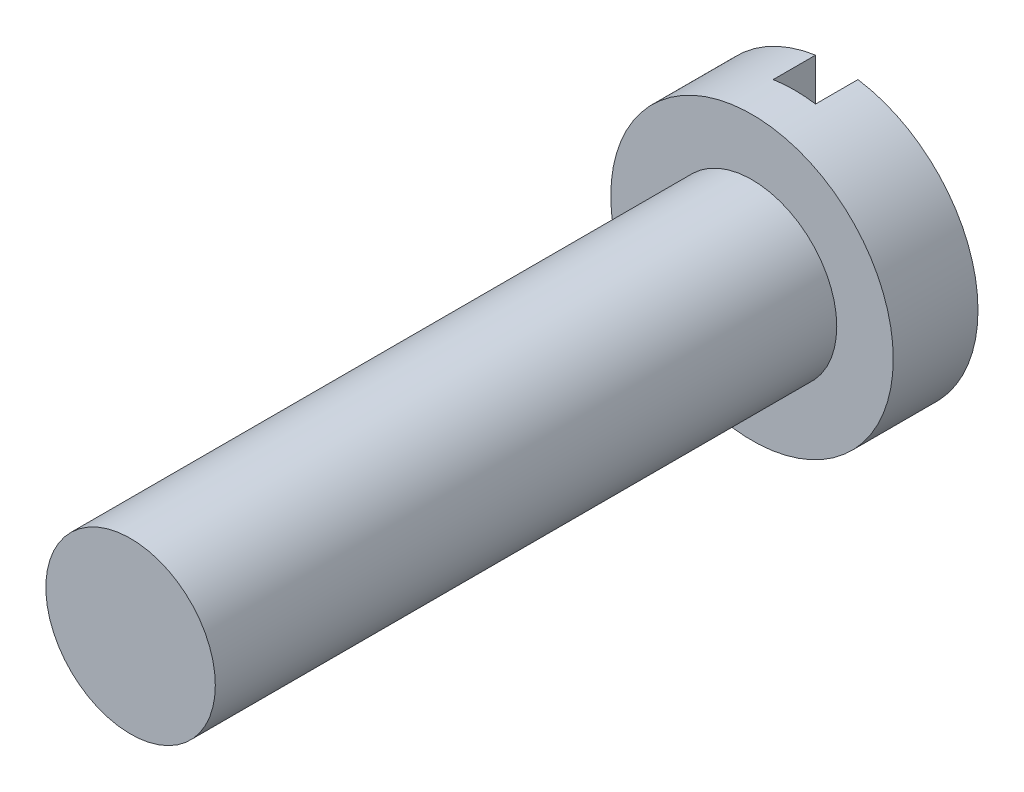
from build123d import *

# Parameters (mm, degrees)
SKETCH_1_R          = 3
EXTRUDE_1_DEPTH     = 22
SKETCH_1_3_R        = 5
EXTRUDE_2_DEPTH     = 3
SKETCH_2_W          = 1.5
SKETCH_2_H          = 10
CUT_EXTRUDE_1_DEPTH = 1.5


with BuildPart() as part:
    # 草图1 → 凸台-拉伸1 (new body)
    with BuildSketch(Plane.XY):
        Circle(SKETCH_1_R)
    extrude(amount=EXTRUDE_1_DEPTH)

    # 草图1<3> → 凸台-拉伸2 (add)
    with BuildSketch(Plane.XY):
        Circle(SKETCH_1_3_R)
    extrude(amount=-EXTRUDE_2_DEPTH)

    # 草图2 → 切除-拉伸1 (cut)
    with BuildSketch(Plane(origin=(0, 0, -3), x_dir=(-1, 0, 0), z_dir=(0, 0, -1))):
        Rectangle(SKETCH_2_W, SKETCH_2_H)
    extrude(amount=-CUT_EXTRUDE_1_DEPTH, mode=Mode.SUBTRACT)


solid = part.part
